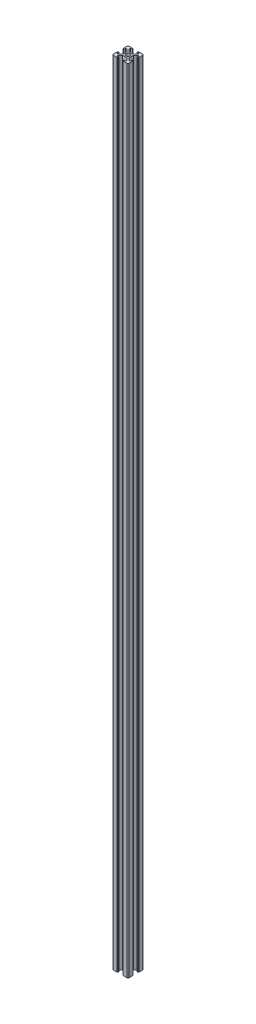
from build123d import *

# Parameters (mm, degrees)
SKETCH1_R                = 2.5
F_20_X_20_X_R1_5_1_DEPTH = 1000


with BuildPart() as part:
    # Sketch1 → 铝型材 20 X 20 X R1.5(1) (new body)
    with BuildSketch(Plane(origin=(0, 0, 0), x_dir=(-1, 0, 0), z_dir=(0, 1, 0))):
        with BuildLine():
            Line((-3.6, 10), (-3.6, 9.5))
            Line((-3.6, 9.5), (-3.1, 9.5))
            Line((-3.1, 9.5), (-3.1, 8.5))
            Line((-3.1, 8.5), (-5.5, 8.5))
            Line((-5.5, 8.5), (-5.5, 6.65))
            Line((-5.5, 6.65), (-2.75, 3.9))
            Line((-2.75, 3.9), (2.75, 3.9))
            Line((2.75, 3.9), (5.5, 6.65))
            Line((5.5, 6.65), (5.5, 8.5))
            Line((5.5, 8.5), (3.1, 8.5))
            Line((3.1, 8.5), (3.1, 9.5))
            Line((3.1, 9.5), (3.6, 9.5))
            Line((3.6, 9.5), (3.6, 10))
            Line((3.6, 10), (8.5, 10))
            ThreePointArc((8.5, 10), (9.560660172, 9.560660172), (10, 8.5))
            Line((10, 8.5), (10, 3.6))
            Line((10, 3.6), (9.5, 3.6))
            Line((9.5, 3.6), (9.5, 3.1))
            Line((9.5, 3.1), (8.5, 3.1))
            Line((8.5, 3.1), (8.5, 5.5))
            Line((8.5, 5.5), (6.65, 5.5))
            Line((6.65, 5.5), (3.9, 2.75))
            Line((3.9, 2.75), (3.9, -2.75))
            Line((3.9, -2.75), (6.65, -5.5))
            Line((6.65, -5.5), (8.5, -5.5))
            Line((8.5, -5.5), (8.5, -3.1))
            Line((8.5, -3.1), (9.5, -3.1))
            Line((9.5, -3.1), (9.5, -3.6))
            Line((9.5, -3.6), (10, -3.6))
            Line((10, -3.6), (10, -8.5))
            ThreePointArc((10, -8.5), (9.560660172, -9.560660172), (8.5, -10))
            Line((8.5, -10), (3.6, -10))
            Line((3.6, -10), (3.6, -9.5))
            Line((3.6, -9.5), (3.1, -9.5))
            Line((3.1, -9.5), (3.1, -8.5))
            Line((3.1, -8.5), (5.5, -8.5))
            Line((5.5, -8.5), (5.5, -6.65))
            Line((5.5, -6.65), (2.75, -3.9))
            Line((2.75, -3.9), (-2.75, -3.9))
            Line((-2.75, -3.9), (-5.5, -6.65))
            Line((-5.5, -6.65), (-5.5, -8.5))
            Line((-5.5, -8.5), (-3.1, -8.5))
            Line((-3.1, -8.5), (-3.1, -9.5))
            Line((-3.1, -9.5), (-3.6, -9.5))
            Line((-3.6, -9.5), (-3.6, -10))
            Line((-3.6, -10), (-8.5, -10))
            ThreePointArc((-8.5, -10), (-9.560660172, -9.560660172), (-10, -8.5))
            Line((-10, -8.5), (-10, -3.6))
            Line((-10, -3.6), (-9.5, -3.6))
            Line((-9.5, -3.6), (-9.5, -3.1))
            Line((-9.5, -3.1), (-8.5, -3.1))
            Line((-8.5, -3.1), (-8.5, -5.5))
            Line((-8.5, -5.5), (-6.65, -5.5))
            Line((-6.65, -5.5), (-3.9, -2.75))
            Line((-3.9, -2.75), (-3.9, 2.75))
            Line((-3.9, 2.75), (-6.65, 5.5))
            Line((-6.65, 5.5), (-8.5, 5.5))
            Line((-8.5, 5.5), (-8.5, 3.1))
            Line((-8.5, 3.1), (-9.5, 3.1))
            Line((-9.5, 3.1), (-9.5, 3.6))
            Line((-9.5, 3.6), (-10, 3.6))
            Line((-10, 3.6), (-10, 8.5))
            ThreePointArc((-10, 8.5), (-9.560660172, 9.560660172), (-8.5, 10))
            Line((-8.5, 10), (-3.6, 10))
        make_face()
        Circle(SKETCH1_R, mode=Mode.SUBTRACT)
    extrude(amount=F_20_X_20_X_R1_5_1_DEPTH)


solid = part.part
